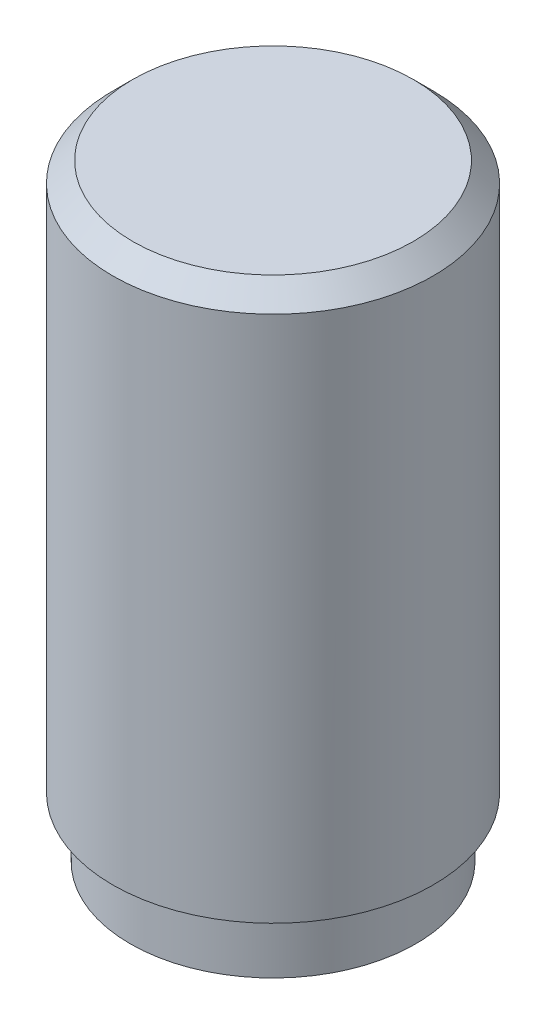
from build123d import *

# Parameters (mm, degrees)
CHAMFER1_SIZE       = 2.54
SKETCH6_R           = 18.2245
SKETCH6_R_2         = 16.9545
BOSS_EXTRUDE2_DEPTH = 3.81


with BuildPart() as part:
    # Sketch2 → Revolve1 (revolve)
    with BuildSketch(Plane.XY):
        Polygon((20.447, 0), (20.447, 69.85), (0, 69.85), (0, 63.5), (16.9545, 63.5), (16.9545, -3.81), (18.2245, -3.81), (18.2245, 0), align=None)
    revolve(axis=Axis((0, 86.868, 0), (0, -1, 0)))

    # Chamfer1
    chamfer1_edges = [part.edges().sort_by_distance(p)[0] for p in [
        (-20.447, 69.85, 0),
    ]]
    chamfer(chamfer1_edges, length=CHAMFER1_SIZE)

    # Sketch6 → Boss-Extrude2 (add)
    with BuildSketch(Plane.XZ.offset(3.81)):
        Circle(SKETCH6_R)
        Circle(SKETCH6_R_2, mode=Mode.SUBTRACT)
    extrude(amount=BOSS_EXTRUDE2_DEPTH)


solid = part.part
